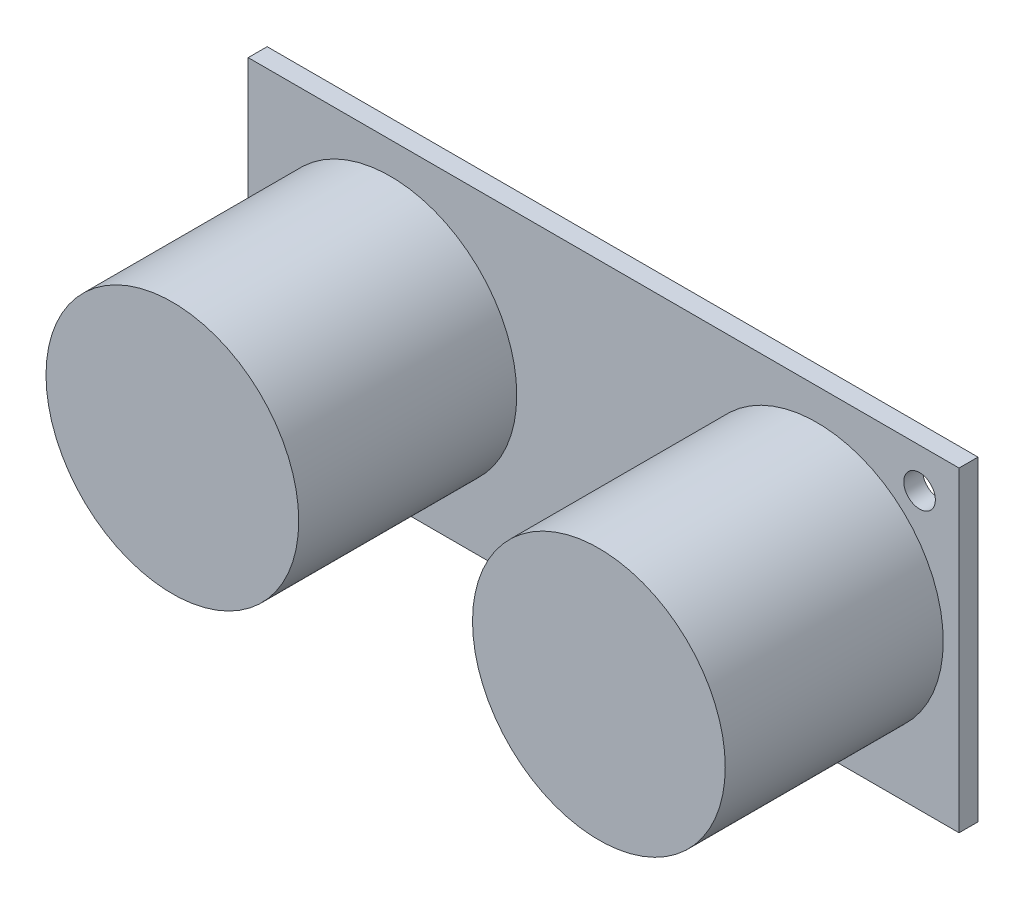
from build123d import *

# Parameters (mm, degrees)
SKETCH1_W           = 45
SKETCH1_H           = 20
SKETCH1_R           = 1
BOSS_EXTRUDE1_DEPTH = 1.2
SKETCH2_R           = 8
BOSS_EXTRUDE2_DEPTH = 13.8


with BuildPart() as part:
    # Sketch1 → Boss-Extrude1 (new body)
    with BuildSketch(Plane.XY):
        Rectangle(SKETCH1_W, SKETCH1_H)
        with Locations((20, 7.5)):
            Circle(SKETCH1_R, mode=Mode.SUBTRACT)
        with Locations((-20, -7.5)):
            Circle(SKETCH1_R, mode=Mode.SUBTRACT)
    extrude(amount=BOSS_EXTRUDE1_DEPTH)

    # Sketch2 → Boss-Extrude2 (add)
    with BuildSketch(Plane.XY.offset(1.2)):
        with Locations((13.5, 0)):
            Circle(SKETCH2_R)
        with Locations((-13.5, 0)):
            Circle(SKETCH2_R)
    extrude(amount=BOSS_EXTRUDE2_DEPTH)


solid = part.part
